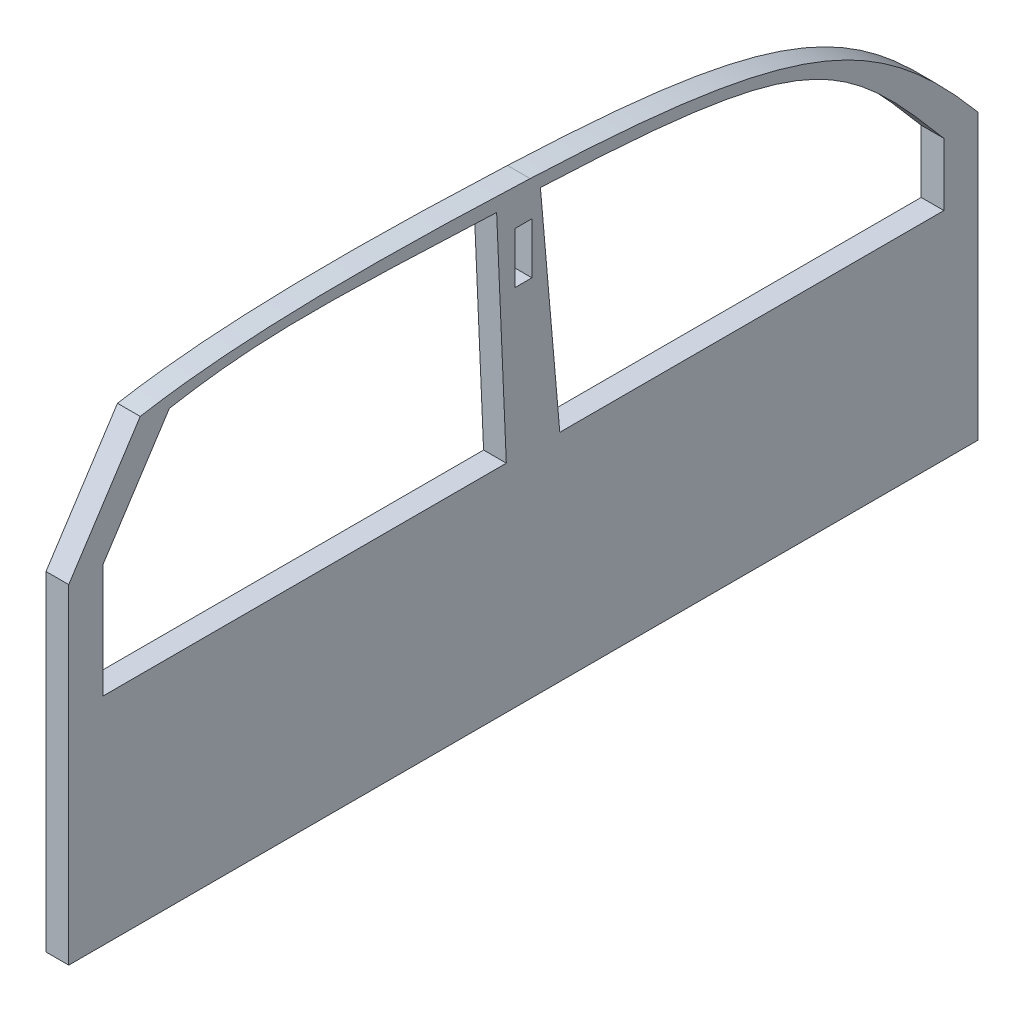
from build123d import *

# Parameters (mm, degrees)
SKETCH_1_W      = 15
SKETCH_1_H      = 45
EXTRUDE_1_DEPTH = 20


with BuildPart() as part:
    # 스케치1 → 보스-돌출1 (new body)
    with BuildSketch(Plane(origin=(0, 0, 0), x_dir=(0, 0, -1), z_dir=(1, 0, 0))):
        with BuildLine():
            Line((-16.859812573, -262.598940355), (783.140187427, -262.598940355))
            Line((783.140187427, -262.598940355), (783.140187427, -12.598940355))
            add(Edge.make_bspline(
                [(783.140187427, -12.598940355), (693.149922071, 94.647281681), (622.224730849, 123.583941687), (389.113479147, 133.761798739)],
                knots=[0, 0, 0, 0, 1, 1, 1, 1], degree=3))
            add(Edge.make_bspline(
                [(389.113479147, 133.761798739), (239.256245909, 140.304706844), (128.104345717, 138.567511957), (46.037032966, 124.096830485)],
                knots=[0, 0, 0, 0, 1, 1, 1, 1], degree=3))
            Line((46.037032966, 124.096830485), (-16.859812573, 27.401059645))
            Line((-16.859812573, 27.401059645), (-16.859812573, -262.598940355))
        make_face()
        with BuildLine():
            Line((71.681693941, 117.401059645), (13.140187427, 27.401059645))
            Line((13.140187427, 27.401059645), (13.140187427, -72.598940355))
            Line((13.140187427, -72.598940355), (368.140187427, -72.598940355))
            Line((368.140187427, -72.598940355), (359.613742981, 122.688744193))
            add(Edge.make_bspline(
                [(71.681693941, 117.401059645), (153.749006692, 131.871741117), (209.756509744, 129.231652298), (359.613742981, 122.688744193)],
                knots=[0, 0, 0, 0, 0.860293328, 0.860293328, 0.860293328, 0.860293328], degree=3))
        make_face(mode=Mode.SUBTRACT)
        with BuildLine():
            Line((753.140187427, -72.598940355), (415.200476814, -72.598940355))
            Line((415.200476814, -72.598940355), (398.140187427, 122.401059645))
            add(Edge.make_bspline(
                [(398.140187427, 122.401059645), (631.251439129, 112.223202593), (663.149922071, 89.647281681), (753.140187427, -17.598940355)],
                knots=[0.027735734, 0.027735734, 0.027735734, 0.027735734, 0.842070206, 0.842070206, 0.842070206, 0.842070206], degree=3))
            Line((753.140187427, -17.598940355), (753.140187427, -72.598940355))
        make_face(mode=Mode.SUBTRACT)
        with Locations((383.140187427, 79.901059645)):
            Rectangle(SKETCH_1_W, SKETCH_1_H, mode=Mode.SUBTRACT)
    extrude(amount=EXTRUDE_1_DEPTH)


solid = part.part
